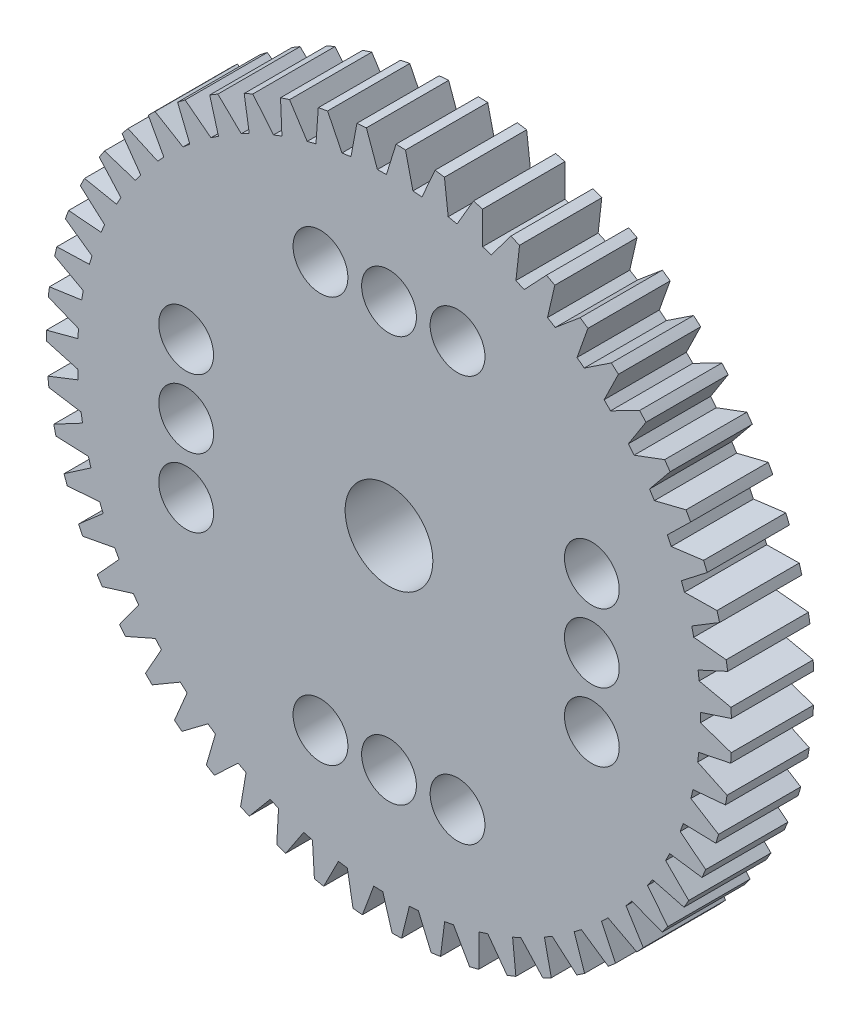
from build123d import *

# Parameters (mm, degrees)
SKETCH1_R           = 12.5
SKETCH1_R_2         = 1.6
SKETCH1_R_3         = 1
BOSS_EXTRUDE1_DEPTH = 3
CUT_EXTRUDE1_DEPTH  = 3
CIRPATTERN1_COUNT   = 55


with BuildPart() as part:
    # Sketch1 → Boss-Extrude1 (new body)
    with BuildSketch(Plane.XY):
        Circle(SKETCH1_R)
        Circle(SKETCH1_R_2, mode=Mode.SUBTRACT)
        with Locations((-2.5, 7.4)):
            Circle(SKETCH1_R_3, mode=Mode.SUBTRACT)
        with Locations((0, 7.4)):
            Circle(SKETCH1_R_3, mode=Mode.SUBTRACT)
        with Locations((2.5, 7.4)):
            Circle(SKETCH1_R_3, mode=Mode.SUBTRACT)
        with Locations((2.5, -7.4)):
            Circle(SKETCH1_R_3, mode=Mode.SUBTRACT)
        with Locations((0, -7.4)):
            Circle(SKETCH1_R_3, mode=Mode.SUBTRACT)
        with Locations((-2.5, -7.4)):
            Circle(SKETCH1_R_3, mode=Mode.SUBTRACT)
        with Locations((7.4, -2.5)):
            Circle(SKETCH1_R_3, mode=Mode.SUBTRACT)
        with Locations((7.4, 0)):
            Circle(SKETCH1_R_3, mode=Mode.SUBTRACT)
        with Locations((7.4, 2.5)):
            Circle(SKETCH1_R_3, mode=Mode.SUBTRACT)
        with Locations((-7.4, 2.5)):
            Circle(SKETCH1_R_3, mode=Mode.SUBTRACT)
        with Locations((-7.4, 0)):
            Circle(SKETCH1_R_3, mode=Mode.SUBTRACT)
        with Locations((-7.4, -2.5)):
            Circle(SKETCH1_R_3, mode=Mode.SUBTRACT)
    extrude(amount=BOSS_EXTRUDE1_DEPTH)

    # Sketch2 → Cut-Extrude1 (cut)
    with BuildSketch(Plane.XY.offset(3)):
        Polygon((-6.543779238, 10.664238289), (-7.447104706, 10.054235749), (-6.495182166, 9.323589817), (-6.221698309, 9.508269485), align=None)
    cut_extrude1 = extrude(amount=-CUT_EXTRUDE1_DEPTH, mode=Mode.SUBTRACT)

    # CirPattern1: Cut-Extrude1 ×55 about axis
    cirpattern1_axis = Axis((0, 0, 0), (0, 0, 1))
    for i in range(1, CIRPATTERN1_COUNT):
        add(cut_extrude1.rotate(cirpattern1_axis, i * 360 / CIRPATTERN1_COUNT), mode=Mode.SUBTRACT)


solid = part.part
